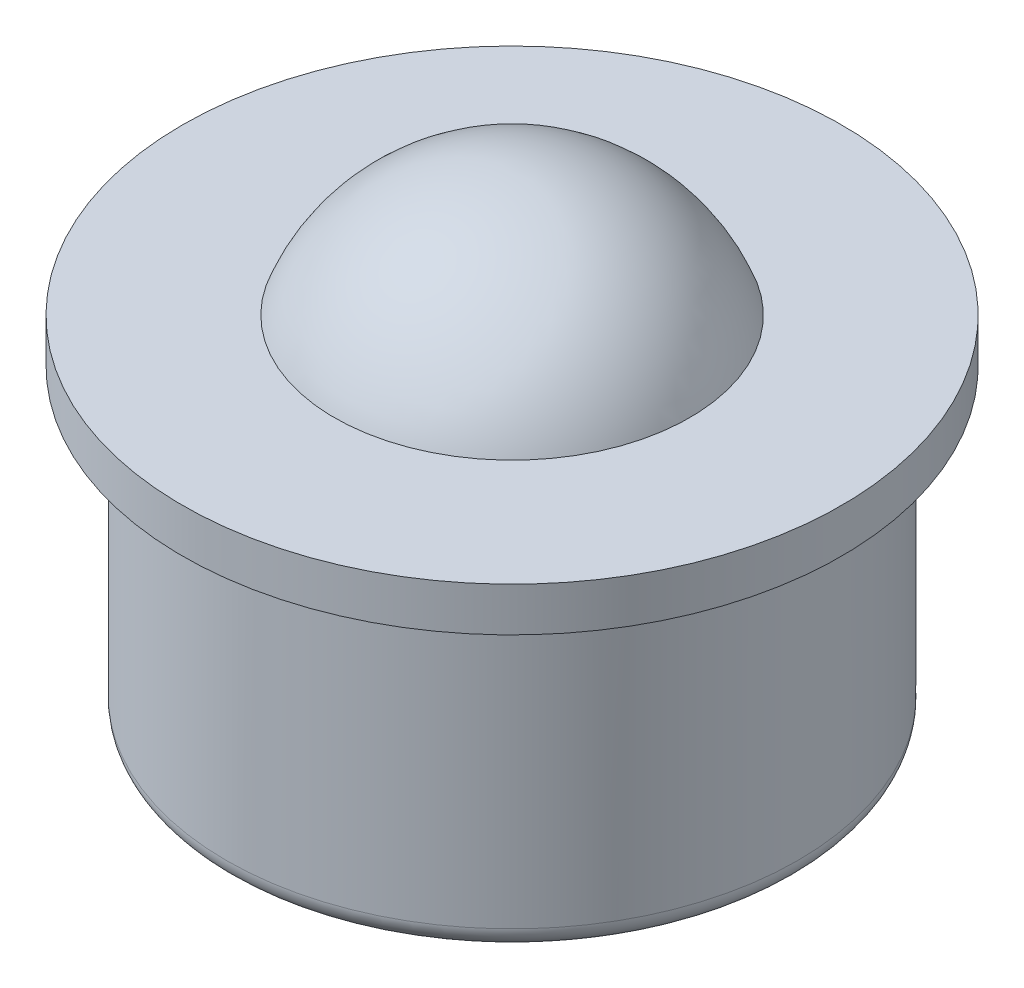
from build123d import *

# Parameters (mm, degrees)
FILLET1_R = 0.5


with BuildPart() as part:
    # Sketch1 → Revolve2 (revolve)
    with BuildSketch(Plane.XY):
        with BuildLine():
            Line((-6.5, 3.5), (-7.5, 3.5))
            Line((-7.5, 3.5), (-7.5, 4.5))
            Line((-7.5, 4.5), (-4.043760626, 4.5))
            ThreePointArc((-4.043760626, 4.5), (-2.459268184, 6.531675661), (0, 7.3))
            Line((0, 7.3), (0, -3.5))
            Line((0, -3.5), (-6.5, -3.5))
            Line((-6.5, -3.5), (-6.5, 3.5))
        make_face()
    revolve(axis=Axis((0, 7.3, 0), (0, -1, 0)))

    # Fillet1
    fillet1_edges = [part.edges().sort_by_distance(p)[0] for p in [
        (6.5, -3.5, 0),
    ]]
    fillet(fillet1_edges, radius=FILLET1_R)


solid = part.part
